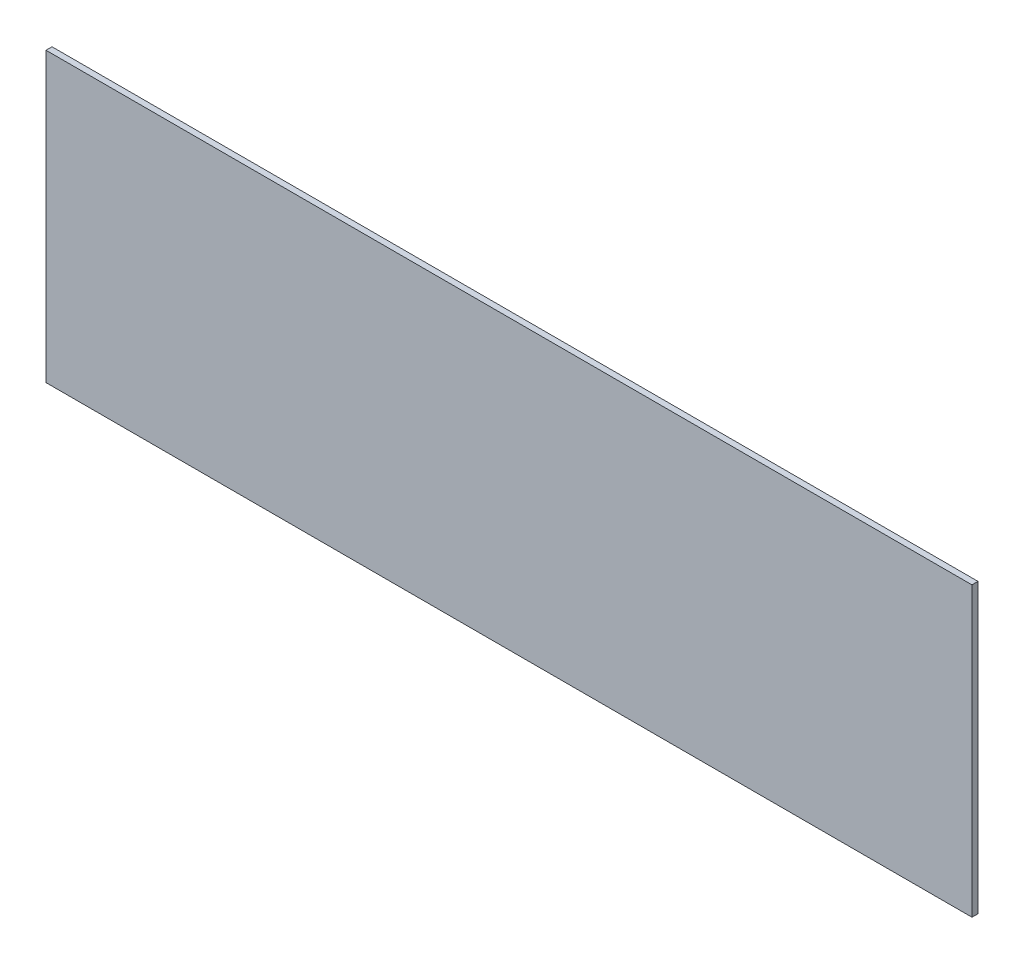
from build123d import *

# Parameters (mm, degrees)
BOSS_EXTRUDE1_DEPTH = 3


with BuildPart() as part:
    # Sketch1 → Boss-Extrude1 (new body)
    with BuildSketch(Plane.XY):
        Polygon((-230, -71.5), (-230, 68.5), (-230, 71.5), (230, 71.5), (230, -71.5), align=None)
    extrude(amount=BOSS_EXTRUDE1_DEPTH)


solid = part.part
